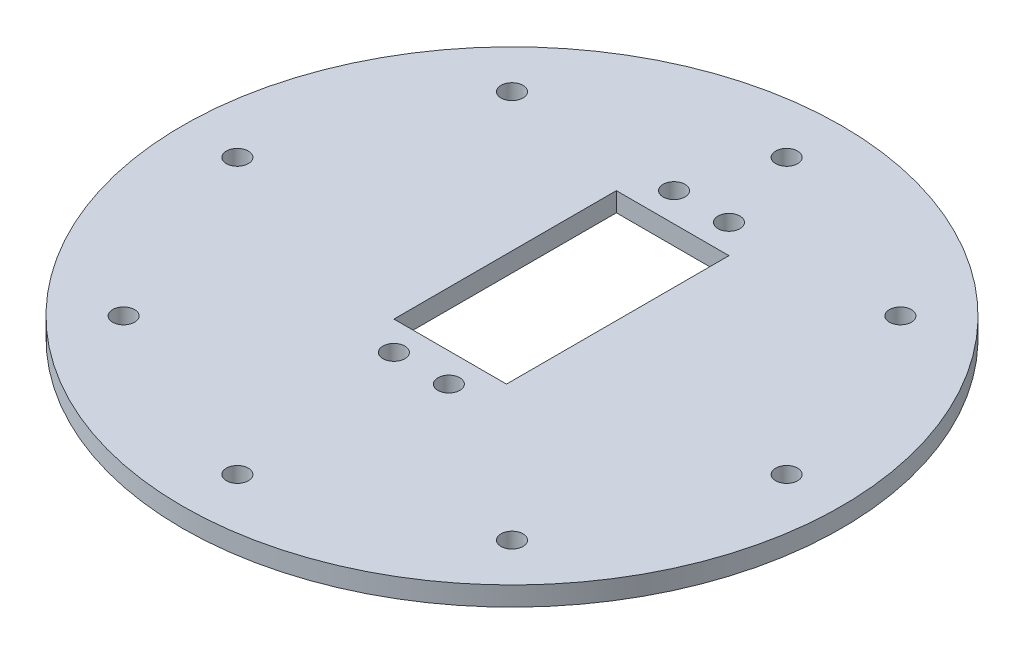
from build123d import *

# Parameters (mm, degrees)
CROQUIS1_R              = 60
SALIENTE_EXTRUIR1_DEPTH = 3.5
CROQUIS2_R              = 2
CORTAR_EXTRUIR1_DEPTH   = 3.5
MATRIZC1_COUNT          = 8
CORTAR_EXTRUIR2_REACH   = 5.5
CROQUIS3_W              = 20.5
CROQUIS3_H              = 40.5
CORTAR_EXTRUIR4_REACH   = 5.5
CROQUIS5_R              = 2


with BuildPart() as part:
    # Croquis1 → Saliente-Extruir1 (new body)
    with BuildSketch(Plane(origin=(0, 0, 0), x_dir=(1, 0, 0), z_dir=(0, 1, 0))):
        Circle(CROQUIS1_R)
    extrude(amount=SALIENTE_EXTRUIR1_DEPTH)

    # Croquis2 → Cortar-Extruir1 (cut)
    with BuildSketch(Plane(origin=(0, 3.5, 0), x_dir=(1, 0, 0), z_dir=(0, 1, 0))):
        with Locations((0, 50)):
            Circle(CROQUIS2_R)
    cortar_extruir1 = extrude(amount=-CORTAR_EXTRUIR1_DEPTH, mode=Mode.SUBTRACT)

    # MatrizC1: Cortar-Extruir1 ×8 about axis
    matrizc1_axis = Axis((0, 0, 0), (0, 1, 0))
    for i in range(1, MATRIZC1_COUNT):
        add(cortar_extruir1.rotate(matrizc1_axis, i * 360 / MATRIZC1_COUNT), mode=Mode.SUBTRACT)

    # Croquis3 → Cortar-Extruir2 (cut, up to next)
    with BuildSketch(Plane(origin=(0, 3.5, 0), x_dir=(1, 0, 0), z_dir=(0, 1, 0)), mode=Mode.PRIVATE) as cortar_extruir2_sk1:
        with Locations((0, 9)):
            Rectangle(CROQUIS3_W, CROQUIS3_H)
    cortar_extruir2_tool1 = extrude(cortar_extruir2_sk1.sketch, amount=-CORTAR_EXTRUIR2_REACH, mode=Mode.PRIVATE) & part.part
    add(cortar_extruir2_tool1.solids().sort_by_distance((0, 3.5, -9))[0], mode=Mode.SUBTRACT)

    # Croquis5 → Cortar-Extruir4 (cut, up to next)
    with BuildSketch(Plane(origin=(0, 3.5, 0), x_dir=(1, 0, 0), z_dir=(0, 1, 0)), mode=Mode.PRIVATE) as cortar_extruir4_sk1:
        with Locations((5, 34.5)):
            Circle(CROQUIS5_R)
    cortar_extruir4_tool1 = extrude(cortar_extruir4_sk1.sketch, amount=-CORTAR_EXTRUIR4_REACH, mode=Mode.PRIVATE) & part.part
    add(cortar_extruir4_tool1.solids().sort_by_distance((5, 3.5, -34.5))[0], mode=Mode.SUBTRACT)
    # Croquis5 → Cortar-Extruir4 (cut, up to next)
    with BuildSketch(Plane(origin=(0, 3.5, 0), x_dir=(1, 0, 0), z_dir=(0, 1, 0)), mode=Mode.PRIVATE) as cortar_extruir4_sk2:
        with Locations((-5, 34.5)):
            Circle(CROQUIS5_R)
    cortar_extruir4_tool2 = extrude(cortar_extruir4_sk2.sketch, amount=-CORTAR_EXTRUIR4_REACH, mode=Mode.PRIVATE) & part.part
    add(cortar_extruir4_tool2.solids().sort_by_distance((-5, 3.5, -34.5))[0], mode=Mode.SUBTRACT)
    # Croquis5 → Cortar-Extruir4 (cut, up to next)
    with BuildSketch(Plane(origin=(0, 3.5, 0), x_dir=(1, 0, 0), z_dir=(0, 1, 0)), mode=Mode.PRIVATE) as cortar_extruir4_sk3:
        with Locations((-5, -16.5)):
            Circle(CROQUIS5_R)
    cortar_extruir4_tool3 = extrude(cortar_extruir4_sk3.sketch, amount=-CORTAR_EXTRUIR4_REACH, mode=Mode.PRIVATE) & part.part
    add(cortar_extruir4_tool3.solids().sort_by_distance((-5, 3.5, 16.5))[0], mode=Mode.SUBTRACT)
    # Croquis5 → Cortar-Extruir4 (cut, up to next)
    with BuildSketch(Plane(origin=(0, 3.5, 0), x_dir=(1, 0, 0), z_dir=(0, 1, 0)), mode=Mode.PRIVATE) as cortar_extruir4_sk4:
        with Locations((5, -16.5)):
            Circle(CROQUIS5_R)
    cortar_extruir4_tool4 = extrude(cortar_extruir4_sk4.sketch, amount=-CORTAR_EXTRUIR4_REACH, mode=Mode.PRIVATE) & part.part
    add(cortar_extruir4_tool4.solids().sort_by_distance((5, 3.5, 16.5))[0], mode=Mode.SUBTRACT)


solid = part.part
